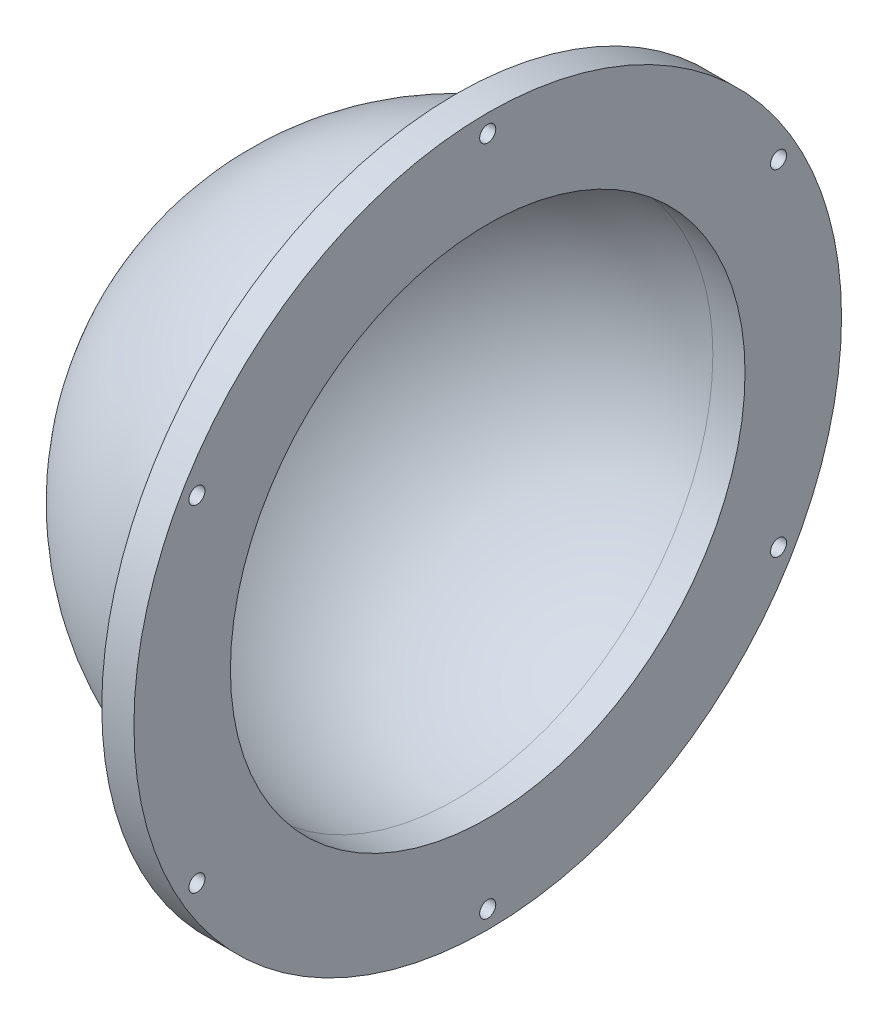
from build123d import *

# Parameters (mm, degrees)
SKETCH_4_R               = 1.25
CUT_EXTRUDE_1_DEPTH      = 6
PATTERN_CIRCULAR_1_COUNT = 6


with BuildPart() as part:
    # 草图2 → 旋转1 (revolve)
    with BuildSketch(Plane(origin=(0, 0, 0), x_dir=(1, 0, 0), z_dir=(0, 1, 0))):
        with BuildLine():
            Line((-45, 0), (-50, 0))
            ThreePointArc((-50, 0), (-36.819805153, 31.819805153), (-5, 45))
            Line((-5, 45), (-5, 55))
            Line((-5, 55), (0, 55))
            Line((0, 55), (0, 40))
            Line((0, 40), (-5, 40))
            ThreePointArc((-5, 40), (-33.284271247, 28.284271247), (-45, 0))
        make_face()
    revolve(axis=Axis((95.822015525, 0, 0), (-1, 0, 0)))

    # 草图4 → 切除-拉伸1 (cut, through all)
    with BuildSketch(Plane.ZY.offset(5)):
        with Locations((0, 52.2)):
            Circle(SKETCH_4_R)
    cut_extrude_1 = extrude(amount=-CUT_EXTRUDE_1_DEPTH, mode=Mode.SUBTRACT)

    # 阵列(圆周)1: 切除-拉伸1 ×6 about axis
    pattern_circular_1_axis = Axis((0, 0, 0), (1, 0, 0))
    for i in range(1, PATTERN_CIRCULAR_1_COUNT):
        add(cut_extrude_1.rotate(pattern_circular_1_axis, i * 360 / PATTERN_CIRCULAR_1_COUNT), mode=Mode.SUBTRACT)


solid = part.part
